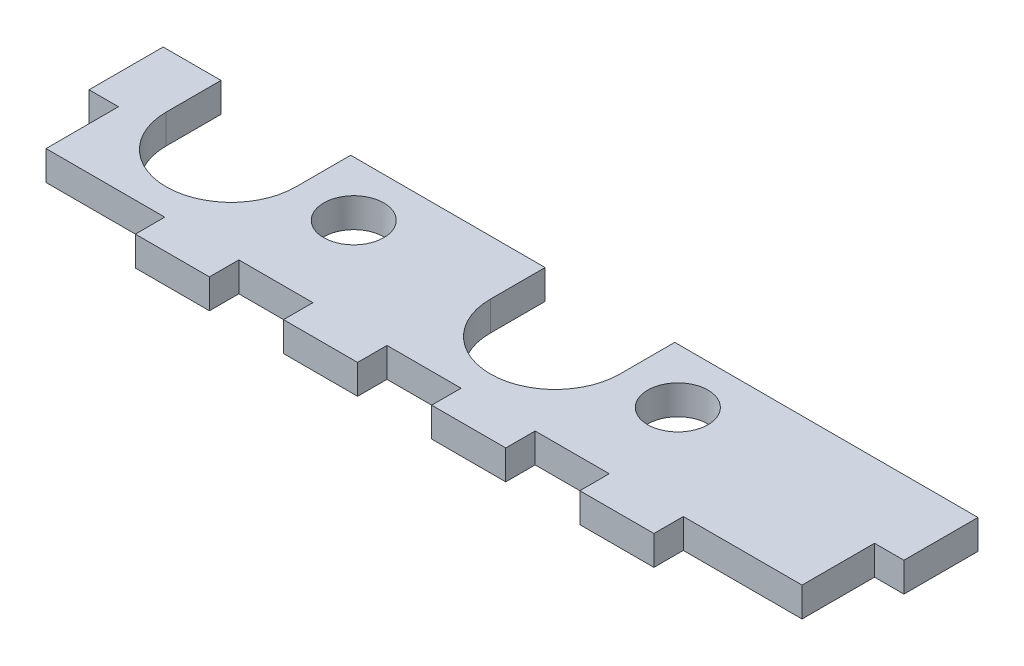
from build123d import *

# Parameters (mm, degrees)
SKETCH3_W           = 88
SKETCH3_H           = 30
BOSS_EXTRUDE1_DEPTH = 3.175
CUT_EXTRUDE1_REACH  = 5.175
SKETCH4_W           = 3.175
SKETCH4_H           = 7.825
SKETCH4_W_2         = 8
SKETCH4_H_2         = 3.175
SKETCH4_H_3         = 11
CUT_EXTRUDE2_REACH  = 5.175
SKETCH5_R           = 3.25
CUT_EXTRUDE3_REACH  = 5.175
SKETCH6_W           = 81.65
SKETCH6_H           = 11
CUT_EXTRUDE4_REACH  = 5.175


with BuildPart() as part:
    # Sketch3 → Boss-Extrude1 (new body)
    with BuildSketch(Plane(origin=(0, 0, 0), x_dir=(1, 0, 0), z_dir=(0, 1, 0))):
        with Locations((44, -15)):
            Rectangle(SKETCH3_W, SKETCH3_H)
    extrude(amount=BOSS_EXTRUDE1_DEPTH)

    # Sketch4 → Cut-Extrude1 (cut, up to next)
    with BuildSketch(Plane(origin=(0, 3.175, 0), x_dir=(1, 0, 0), z_dir=(0, 1, 0)), mode=Mode.PRIVATE) as cut_extrude1_sk1:
        with Locations((1.5875, -22.9125)):
            Rectangle(SKETCH4_W, SKETCH4_H)
    cut_extrude1_tool1 = extrude(cut_extrude1_sk1.sketch, amount=-CUT_EXTRUDE1_REACH, mode=Mode.PRIVATE) & part.part
    add(cut_extrude1_tool1.solids().sort_by_distance((1.5875, 3.175, 22.9125))[0], mode=Mode.SUBTRACT)
    # Sketch4 → Cut-Extrude1 (cut, up to next)
    with BuildSketch(Plane(origin=(0, 3.175, 0), x_dir=(1, 0, 0), z_dir=(0, 1, 0)), mode=Mode.PRIVATE) as cut_extrude1_sk2:
        Polygon((0, -30), (16, -30), (16, -26.825), (3.175, -26.825), (0, -26.825), align=None)
    cut_extrude1_tool2 = extrude(cut_extrude1_sk2.sketch, amount=-CUT_EXTRUDE1_REACH, mode=Mode.PRIVATE) & part.part
    add(cut_extrude1_tool2.solids().sort_by_distance((8, 3.175, 28.4125))[0], mode=Mode.SUBTRACT)
    # Sketch4 → Cut-Extrude1 (cut, up to next)
    with BuildSketch(Plane(origin=(0, 3.175, 0), x_dir=(1, 0, 0), z_dir=(0, 1, 0)), mode=Mode.PRIVATE) as cut_extrude1_sk3:
        with Locations((28, -28.4125)):
            Rectangle(SKETCH4_W_2, SKETCH4_H_2)
    cut_extrude1_tool3 = extrude(cut_extrude1_sk3.sketch, amount=-CUT_EXTRUDE1_REACH, mode=Mode.PRIVATE) & part.part
    add(cut_extrude1_tool3.solids().sort_by_distance((28, 3.175, 28.4125))[0], mode=Mode.SUBTRACT)
    # Sketch4 → Cut-Extrude1 (cut, up to next)
    with BuildSketch(Plane(origin=(0, 3.175, 0), x_dir=(1, 0, 0), z_dir=(0, 1, 0)), mode=Mode.PRIVATE) as cut_extrude1_sk4:
        with Locations((44, -28.4125)):
            Rectangle(SKETCH4_W_2, SKETCH4_H_2)
    cut_extrude1_tool4 = extrude(cut_extrude1_sk4.sketch, amount=-CUT_EXTRUDE1_REACH, mode=Mode.PRIVATE) & part.part
    add(cut_extrude1_tool4.solids().sort_by_distance((44, 3.175, 28.4125))[0], mode=Mode.SUBTRACT)
    # Sketch4 → Cut-Extrude1 (cut, up to next)
    with BuildSketch(Plane(origin=(0, 3.175, 0), x_dir=(1, 0, 0), z_dir=(0, 1, 0)), mode=Mode.PRIVATE) as cut_extrude1_sk5:
        with Locations((60, -28.4125)):
            Rectangle(SKETCH4_W_2, SKETCH4_H_2)
    cut_extrude1_tool5 = extrude(cut_extrude1_sk5.sketch, amount=-CUT_EXTRUDE1_REACH, mode=Mode.PRIVATE) & part.part
    add(cut_extrude1_tool5.solids().sort_by_distance((60, 3.175, 28.4125))[0], mode=Mode.SUBTRACT)
    # Sketch4 → Cut-Extrude1 (cut, up to next)
    with BuildSketch(Plane(origin=(0, 3.175, 0), x_dir=(1, 0, 0), z_dir=(0, 1, 0)), mode=Mode.PRIVATE) as cut_extrude1_sk6:
        with Locations((86.4125, -22.9125)):
            Rectangle(SKETCH4_W, SKETCH4_H)
    cut_extrude1_tool6 = extrude(cut_extrude1_sk6.sketch, amount=-CUT_EXTRUDE1_REACH, mode=Mode.PRIVATE) & part.part
    add(cut_extrude1_tool6.solids().sort_by_distance((86.4125, 3.175, 22.9125))[0], mode=Mode.SUBTRACT)
    # Sketch4 → Cut-Extrude1 (cut, up to next)
    with BuildSketch(Plane(origin=(0, 3.175, 0), x_dir=(1, 0, 0), z_dir=(0, 1, 0)), mode=Mode.PRIVATE) as cut_extrude1_sk7:
        with Locations((86.4125, -5.5)):
            Rectangle(SKETCH4_W, SKETCH4_H_3)
    cut_extrude1_tool7 = extrude(cut_extrude1_sk7.sketch, amount=-CUT_EXTRUDE1_REACH, mode=Mode.PRIVATE) & part.part
    add(cut_extrude1_tool7.solids().sort_by_distance((86.4125, 3.175, 5.5))[0], mode=Mode.SUBTRACT)
    # Sketch4 → Cut-Extrude1 (cut, up to next)
    with BuildSketch(Plane(origin=(0, 3.175, 0), x_dir=(1, 0, 0), z_dir=(0, 1, 0)), mode=Mode.PRIVATE) as cut_extrude1_sk8:
        Polygon((72, -26.825), (72, -30), (88, -30), (88, -26.825), (84.825, -26.825), align=None)
    cut_extrude1_tool8 = extrude(cut_extrude1_sk8.sketch, amount=-CUT_EXTRUDE1_REACH, mode=Mode.PRIVATE) & part.part
    add(cut_extrude1_tool8.solids().sort_by_distance((80, 3.175, 28.4125))[0], mode=Mode.SUBTRACT)
    # Sketch4 → Cut-Extrude1 (cut, up to next)
    with BuildSketch(Plane(origin=(0, 3.175, 0), x_dir=(1, 0, 0), z_dir=(0, 1, 0)), mode=Mode.PRIVATE) as cut_extrude1_sk9:
        with Locations((1.5875, -5.5)):
            Rectangle(SKETCH4_W, SKETCH4_H_3)
    cut_extrude1_tool9 = extrude(cut_extrude1_sk9.sketch, amount=-CUT_EXTRUDE1_REACH, mode=Mode.PRIVATE) & part.part
    add(cut_extrude1_tool9.solids().sort_by_distance((1.5875, 3.175, 5.5))[0], mode=Mode.SUBTRACT)

    # Sketch5 → Cut-Extrude2 (cut, up to next)
    with BuildSketch(Plane(origin=(0, 3.175, 0), x_dir=(1, 0, 0), z_dir=(0, 1, 0)), mode=Mode.PRIVATE) as cut_extrude2_sk1:
        with Locations((61.5, -16.915)):
            Circle(SKETCH5_R)
    cut_extrude2_tool1 = extrude(cut_extrude2_sk1.sketch, amount=-CUT_EXTRUDE2_REACH, mode=Mode.PRIVATE) & part.part
    add(cut_extrude2_tool1.solids().sort_by_distance((61.5, 3.175, 16.915))[0], mode=Mode.SUBTRACT)
    # Sketch5 → Cut-Extrude2 (cut, up to next)
    with BuildSketch(Plane(origin=(0, 3.175, 0), x_dir=(1, 0, 0), z_dir=(0, 1, 0)), mode=Mode.PRIVATE) as cut_extrude2_sk2:
        with Locations((26.5, -16.915)):
            Circle(SKETCH5_R)
    cut_extrude2_tool2 = extrude(cut_extrude2_sk2.sketch, amount=-CUT_EXTRUDE2_REACH, mode=Mode.PRIVATE) & part.part
    add(cut_extrude2_tool2.solids().sort_by_distance((26.5, 3.175, 16.915))[0], mode=Mode.SUBTRACT)

    # Sketch6 → Cut-Extrude3 (cut, up to next)
    with BuildSketch(Plane(origin=(0, 3.175, 0), x_dir=(1, 0, 0), z_dir=(0, 1, 0)), mode=Mode.PRIVATE) as cut_extrude3_sk1:
        with Locations((44, -5.5)):
            Rectangle(SKETCH6_W, SKETCH6_H)
    cut_extrude3_tool1 = extrude(cut_extrude3_sk1.sketch, amount=-CUT_EXTRUDE3_REACH, mode=Mode.PRIVATE) & part.part
    add(cut_extrude3_tool1.solids().sort_by_distance((44, 3.175, 5.5))[0], mode=Mode.SUBTRACT)

    # Sketch7 → Cut-Extrude4 (cut, up to next)
    with BuildSketch(Plane(origin=(0, 3.175, 0), x_dir=(1, 0, 0), z_dir=(0, 1, 0)), mode=Mode.PRIVATE) as cut_extrude4_sk1:
        with BuildLine():
            Line((6.25, -16.915), (6.25, -11))
            Line((6.25, -11), (20.25, -11))
            Line((20.25, -11), (20.25, -16.915))
            ThreePointArc((20.25, -16.915), (13.25, -23.915), (6.25, -16.915))
        make_face()
    cut_extrude4_tool1 = extrude(cut_extrude4_sk1.sketch, amount=-CUT_EXTRUDE4_REACH, mode=Mode.PRIVATE) & part.part
    add(cut_extrude4_tool1.solids().sort_by_distance((13.25, 3.175, 16.813335))[0], mode=Mode.SUBTRACT)
    # Sketch7 → Cut-Extrude4 (cut, up to next)
    with BuildSketch(Plane(origin=(0, 3.175, 0), x_dir=(1, 0, 0), z_dir=(0, 1, 0)), mode=Mode.PRIVATE) as cut_extrude4_sk2:
        with BuildLine():
            Line((41.25, -16.915), (41.25, -11))
            Line((41.25, -11), (55.25, -11))
            Line((55.25, -11), (55.25, -16.915))
            ThreePointArc((55.25, -16.915), (48.25, -23.915), (41.25, -16.915))
        make_face()
    cut_extrude4_tool2 = extrude(cut_extrude4_sk2.sketch, amount=-CUT_EXTRUDE4_REACH, mode=Mode.PRIVATE) & part.part
    add(cut_extrude4_tool2.solids().sort_by_distance((48.25, 3.175, 16.813335))[0], mode=Mode.SUBTRACT)


solid = part.part
